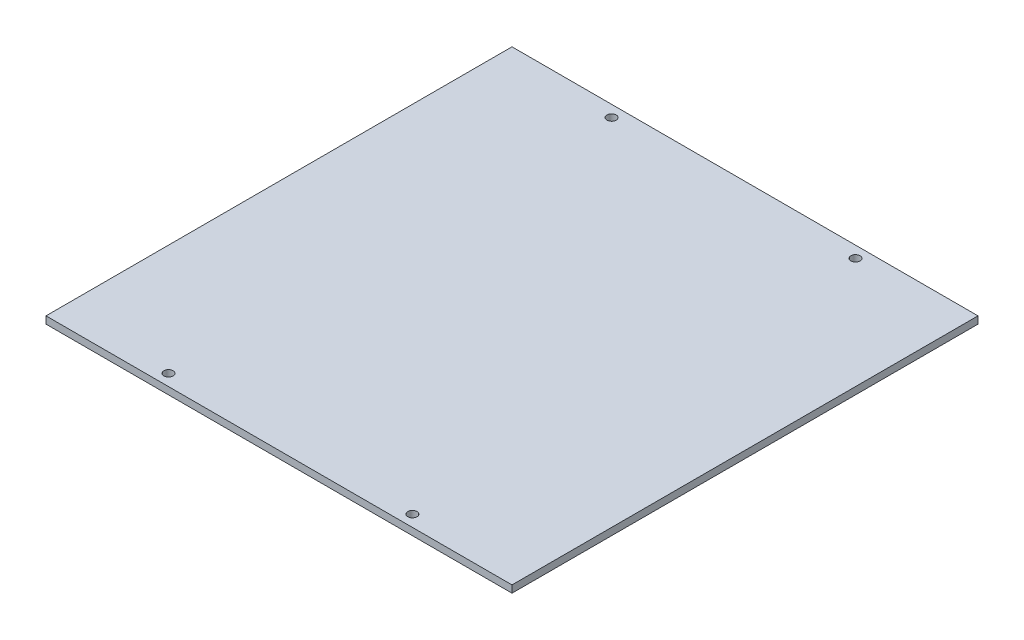
from build123d import *

# Parameters (mm, degrees)
SKETCH1_W           = 101.6
SKETCH1_H           = 101.6
SKETCH1_R           = 1
BOSS_EXTRUDE1_DEPTH = 1.57


with BuildPart() as part:
    # Sketch1 → Boss-Extrude1 (new body)
    with BuildSketch(Plane(origin=(0, 0, 0), x_dir=(1, 0, 0), z_dir=(0, 1, 0))):
        Rectangle(SKETCH1_W, SKETCH1_H)
        with Locations((-26.5875, -48.3)):
            Circle(SKETCH1_R, mode=Mode.SUBTRACT)
        with Locations((-26.5875, 48.3)):
            Circle(SKETCH1_R, mode=Mode.SUBTRACT)
        with Locations((26.5875, 48.3)):
            Circle(SKETCH1_R, mode=Mode.SUBTRACT)
        with Locations((26.5875, -48.3)):
            Circle(SKETCH1_R, mode=Mode.SUBTRACT)
    extrude(amount=BOSS_EXTRUDE1_DEPTH)


solid = part.part
